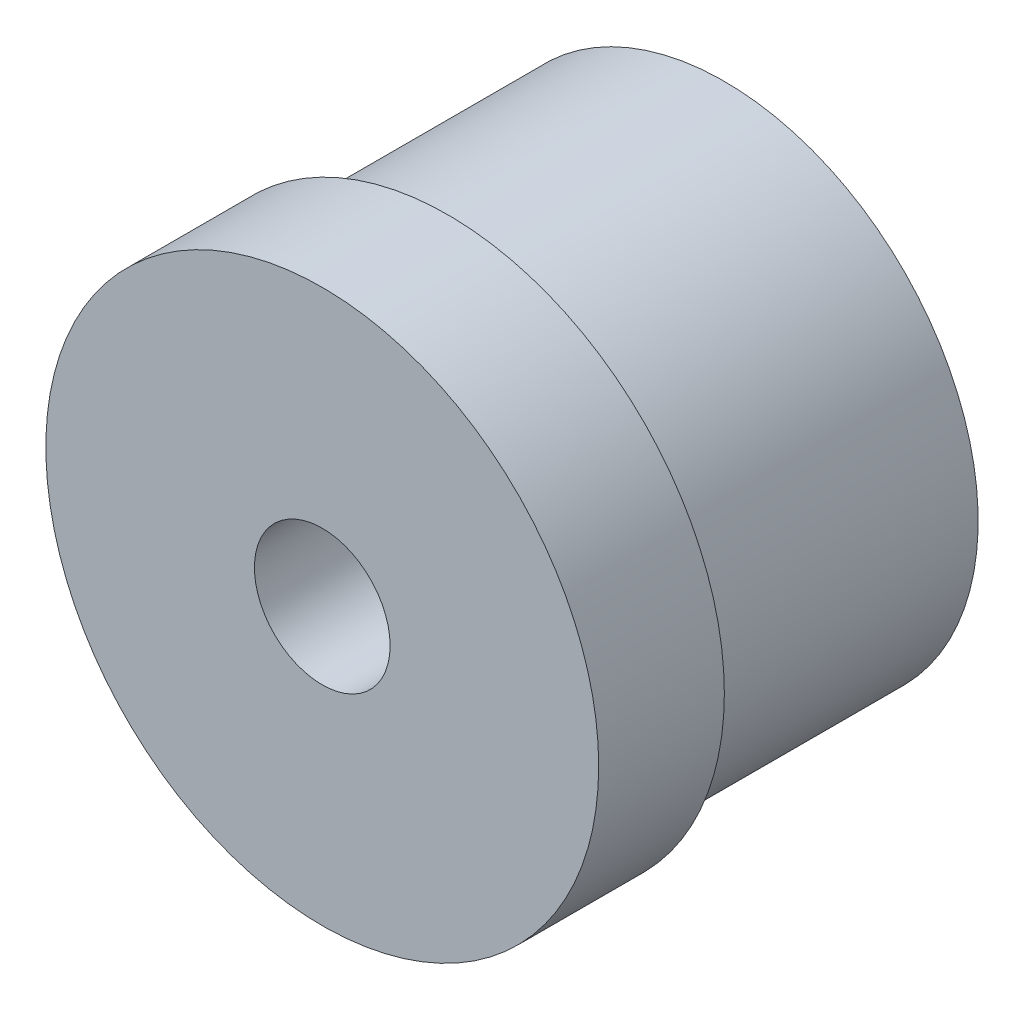
from build123d import *

# Parameters (mm, degrees)
SKETCH3_R           = 11
BOSS_EXTRUDE1_DEPTH = 5
SKETCH4_R           = 10.1
BOSS_EXTRUDE2_DEPTH = 11
SKETCH5_R           = 2.7
CUT_EXTRUDE1_DEPTH  = 17


with BuildPart() as part:
    # Sketch3 → Boss-Extrude1 (new body)
    with BuildSketch(Plane.XY):
        Circle(SKETCH3_R)
    extrude(amount=BOSS_EXTRUDE1_DEPTH)

    # Sketch4 → Boss-Extrude2 (add)
    with BuildSketch(Plane(origin=(0, 0, 0), x_dir=(-1, 0, 0), z_dir=(0, 0, -1))):
        Circle(SKETCH4_R)
    extrude(amount=BOSS_EXTRUDE2_DEPTH)

    # Sketch5 → Cut-Extrude1 (cut, through all)
    with BuildSketch(Plane.XY.offset(5)):
        Circle(SKETCH5_R)
    extrude(amount=-CUT_EXTRUDE1_DEPTH, mode=Mode.SUBTRACT)


solid = part.part
